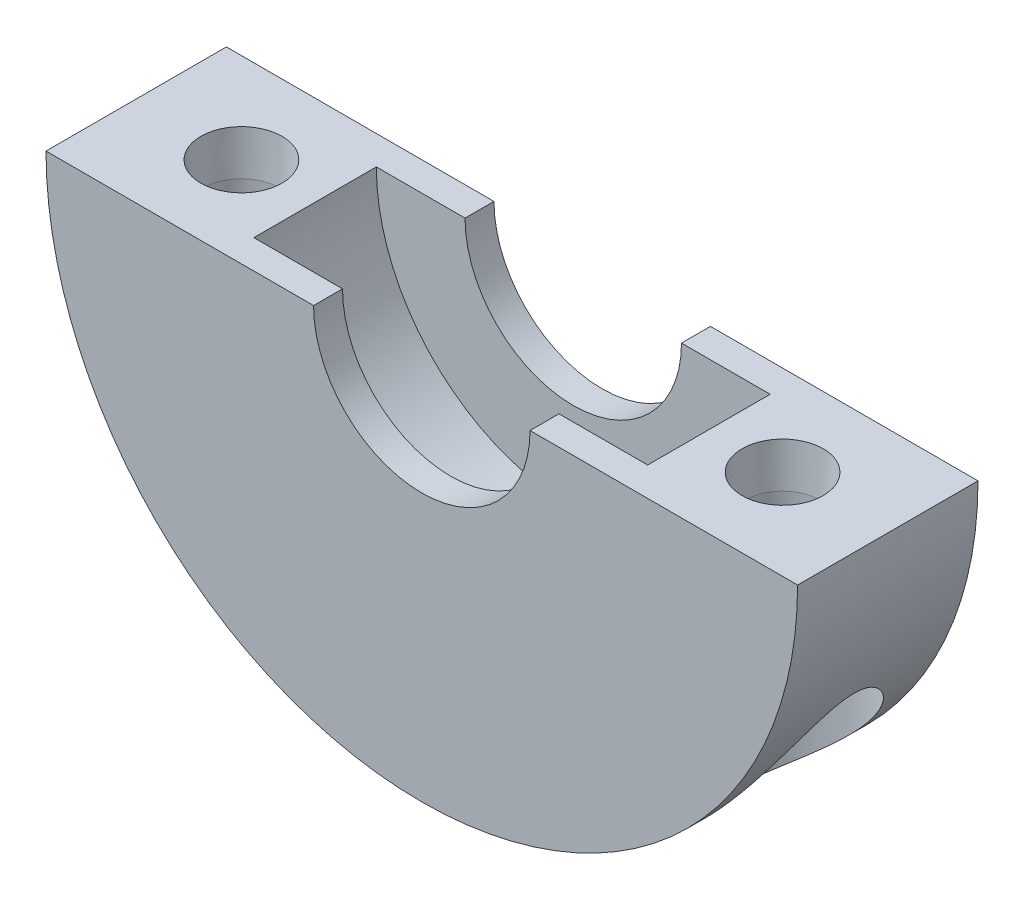
from build123d import *

# Parameters (mm, degrees)
BOSS_EXTRUDE1_DEPTH                          = 12
SKETCH2_R                                    = 4.75
CUT_EXTRUDE1_DEPTH                           = 35
SKETCH3_R                                    = 2.05
CUT_EXTRUDE2_DEPTH                           = 35
SKETCH4_W                                    = 5.9
SKETCH4_H                                    = 8.15
CSK_FOR_M3_CROSS_COUNTERSUNK_HEAD_SC_2_COUNT = 2
CSK_FOR_M3_CROSS_COUNTERSUNK_HEAD_SC_2_PITCH = 36


with BuildPart() as part:
    # Sketch1 → Boss-Extrude1 (new body)
    with BuildSketch(Plane.XY):
        with BuildLine():
            Line((-9.1, 0), (-25, 0))
            ThreePointArc((-25, 0), (0, -25), (25, 0))
            Line((25, 0), (9.211282306, 0))
            Line((9.211282306, 0), (9.1, 0))
            Line((9.1, 0), (-9.1, 0))
        make_face()
    extrude(amount=BOSS_EXTRUDE1_DEPTH)

    # Sketch2 → Cut-Extrude1 (cut)
    with BuildSketch(Plane(origin=(0, -40, 0), x_dir=(1, 0, 0), z_dir=(0, 1, 0))):
        with Locations((18, -6)):
            Circle(SKETCH2_R)
        with Locations((-18, -6)):
            Circle(SKETCH2_R)
    extrude(amount=CUT_EXTRUDE1_DEPTH, mode=Mode.SUBTRACT)

    # Sketch3 → Cut-Extrude2 (cut)
    with BuildSketch(Plane.XZ.offset(5)):
        with Locations((18, 6)):
            Circle(SKETCH3_R)
        with Locations((-18, 6)):
            Circle(SKETCH3_R)
    extrude(amount=-CUT_EXTRUDE2_DEPTH, mode=Mode.SUBTRACT)

    # Sketch4 → Cut-Revolve1 (revolve, cut)
    with BuildSketch(Plane(origin=(0, 0, 0), x_dir=(1, 0, 0), z_dir=(0, 1, 0))):
        Polygon((0, -12), (0, 0), (-7.2, 0), (-7.2, -1.925), (-7.2, -10.075), (-7.2, -12), align=None)
        with Locations((-10.15, -6)):
            Rectangle(SKETCH4_W, SKETCH4_H)
    revolve(axis=Axis((0, 0, 0), (0, 0, 1)), mode=Mode.SUBTRACT)

    # Sketch6 → CSK for M3 Cross Countersunk Head Screw1 (revolve, cut)
    with BuildSketch(Plane(origin=(18, 0, 6), x_dir=(0, 0, 1), z_dir=(1, 0, 0))):
        Polygon((0, 0), (0, 25), (2.5, 25), (2.5, 2.860133251), (2.7, 0), align=None)
    csk_for_m3_cross_countersunk_head_screw1 = revolve(axis=Axis((18, 6.35, 6), (0, -1, 0)), mode=Mode.SUBTRACT)

    # CSK for M3 Cross Countersunk Head Sc 2: CSK for M3 Cross Countersunk Head Screw1 ×2
    with Locations(*[(-i * CSK_FOR_M3_CROSS_COUNTERSUNK_HEAD_SC_2_PITCH, 0, 0) for i in range(1, CSK_FOR_M3_CROSS_COUNTERSUNK_HEAD_SC_2_COUNT)]):
        add(csk_for_m3_cross_countersunk_head_screw1, mode=Mode.SUBTRACT)


solid = part.part
